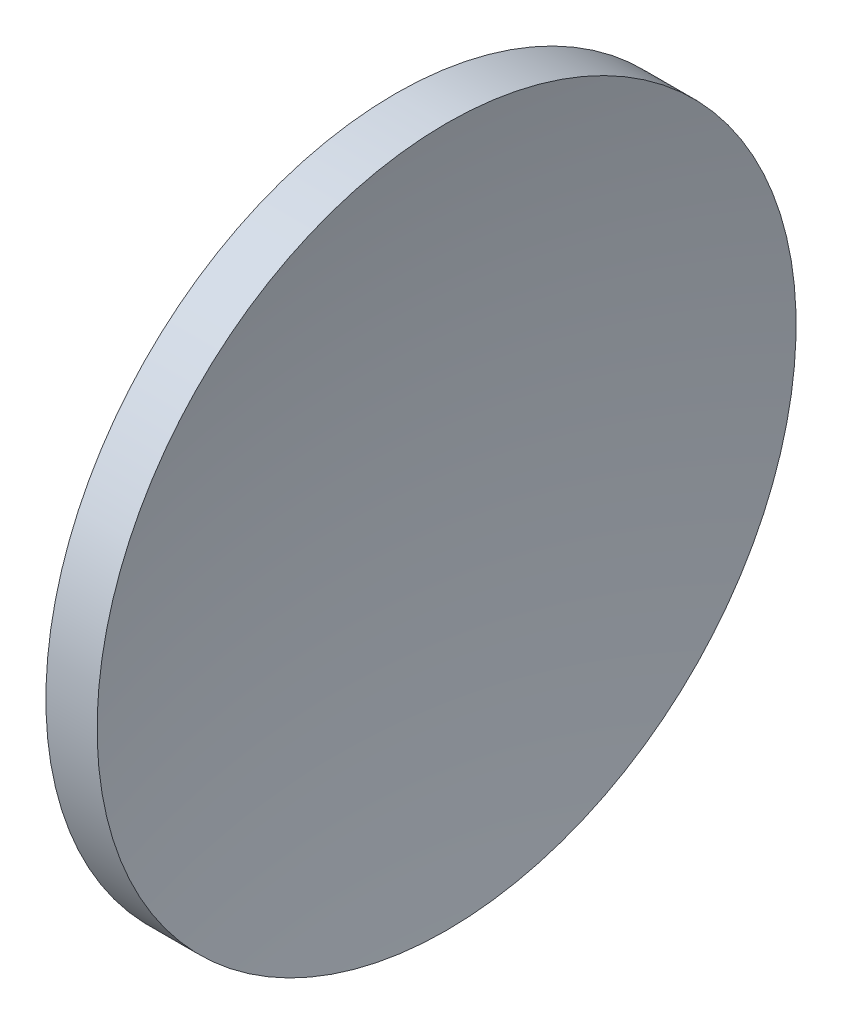
from build123d import *


with BuildPart() as part:
    # 草图1 → 旋转1 (revolve)
    with BuildSketch(Plane.XY):
        with BuildLine():
            Line((249.107906437, 155.433680942), (252.77071281, 155.433680942))
            ThreePointArc((252.77071281, 155.433680942), (250.84361688, 142.999644186), (250.198995672, 130.433680942))
            Line((250.198995672, 130.433680942), (245.198995672, 130.433680942))
            ThreePointArc((245.198995672, 130.433680942), (246.182124105, 143.085554157), (249.107906437, 155.433680942))
        make_face()
    revolve(axis=Axis((231.888982596, 130.433680942, 0), (1, 0, 0)))


solid = part.part
